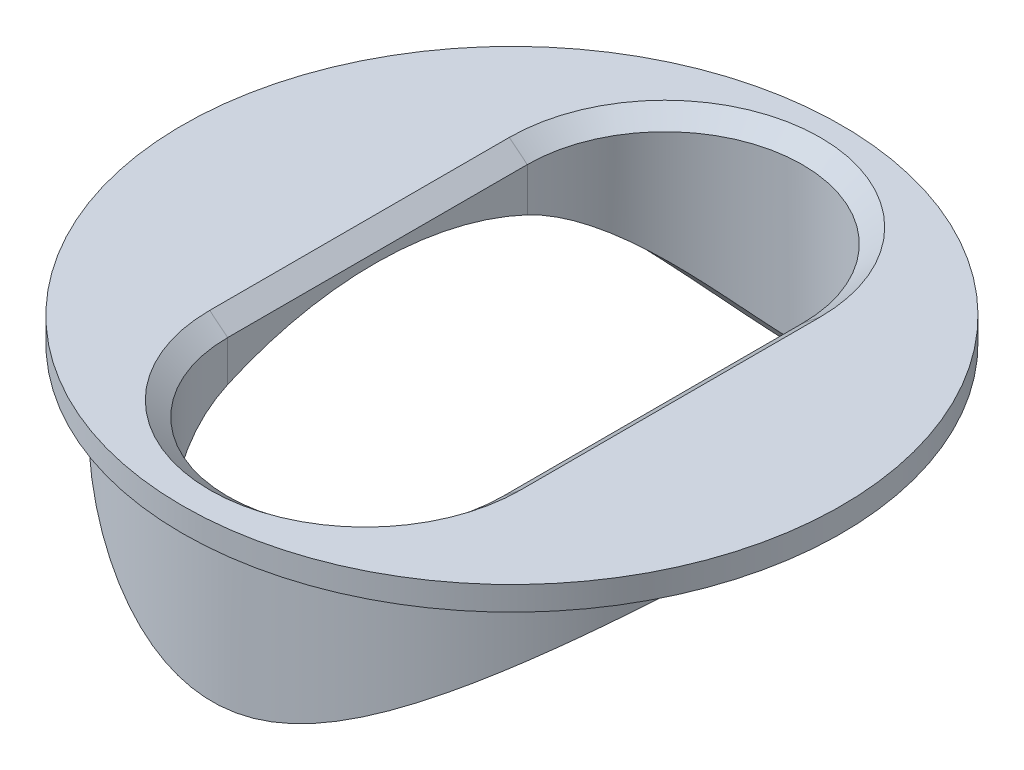
from build123d import *

# Parameters (mm, degrees)
SKETCH1_R               = 5
BOSS_EXTRUDE1_DEPTH     = 5
SKETCH2_R               = 5.5
BOSS_EXTRUDE2_DEPTH     = 0.4
CUT_EXTRUDE1_DEPTH      = 6.4
SKETCH5_R               = 6
CUT_EXTRUDE2_DEPTH      = 6.5
CUT_EXTRUDE2_DEPTH_BACK = 6.5
CHAMFER4_SIZE           = 0.3
CHAMFER4_SIZE2          = 0.24293521


with BuildPart() as part:
    # Sketch1 → Boss-Extrude1 (new body)
    with BuildSketch(Plane(origin=(0, 0, 0), x_dir=(1, 0, 0), z_dir=(0, 1, 0))):
        Circle(SKETCH1_R)
    extrude(amount=BOSS_EXTRUDE1_DEPTH)

    # Sketch2 → Boss-Extrude2 (add)
    with BuildSketch(Plane(origin=(0, 5, 0), x_dir=(1, 0, 0), z_dir=(0, 1, 0))):
        Circle(SKETCH2_R)
    extrude(amount=BOSS_EXTRUDE2_DEPTH)

    # Sketch4 → Cut-Extrude1 (cut, through all)
    with BuildSketch(Plane(origin=(0, 5.4, 0), x_dir=(1, 0, 0), z_dir=(0, 1, 0))):
        with BuildLine():
            Line((2.295250379, 2.551364647), (2.295250379, -2.448635353))
            ThreePointArc((2.295250379, -2.448635353), (0, -4.743885732), (-2.295250379, -2.448635353))
            Line((-2.295250379, -2.448635353), (-2.295250379, 2.551364647))
            ThreePointArc((-2.295250379, 2.551364647), (0, 4.846615026), (2.295250379, 2.551364647))
        make_face()
    extrude(amount=-CUT_EXTRUDE1_DEPTH, mode=Mode.SUBTRACT)

    # Sketch5 → Cut-Extrude2 (cut, two sides)
    with BuildSketch(Plane(origin=(0, 0, 0), x_dir=(0, 0, -1), z_dir=(1, 0, 0))) as cut_extrude2_sk:
        with Locations((0, -1)):
            Circle(SKETCH5_R)
    extrude(amount=CUT_EXTRUDE2_DEPTH, mode=Mode.SUBTRACT)
    extrude(cut_extrude2_sk.sketch, amount=-CUT_EXTRUDE2_DEPTH_BACK, mode=Mode.SUBTRACT)

    # Chamfer4
    chamfer4_edges = [part.edges().sort_by_distance(p)[0] for p in [
        (0, 5.4, -4.846615026),
        (-2.295250379, 5.4, -0.051364647),
        (0, 5.4, 4.743885732),
        (2.295250379, 5.4, -0.051364647),
    ]]
    chamfer4_side = [part.faces().sort_by_distance(p)[0] for p in [
        (-5.344436508, 5.4, 0),
    ]]
    chamfer(chamfer4_edges, length=CHAMFER4_SIZE, length2=CHAMFER4_SIZE2, reference=chamfer4_side[0])


solid = part.part
